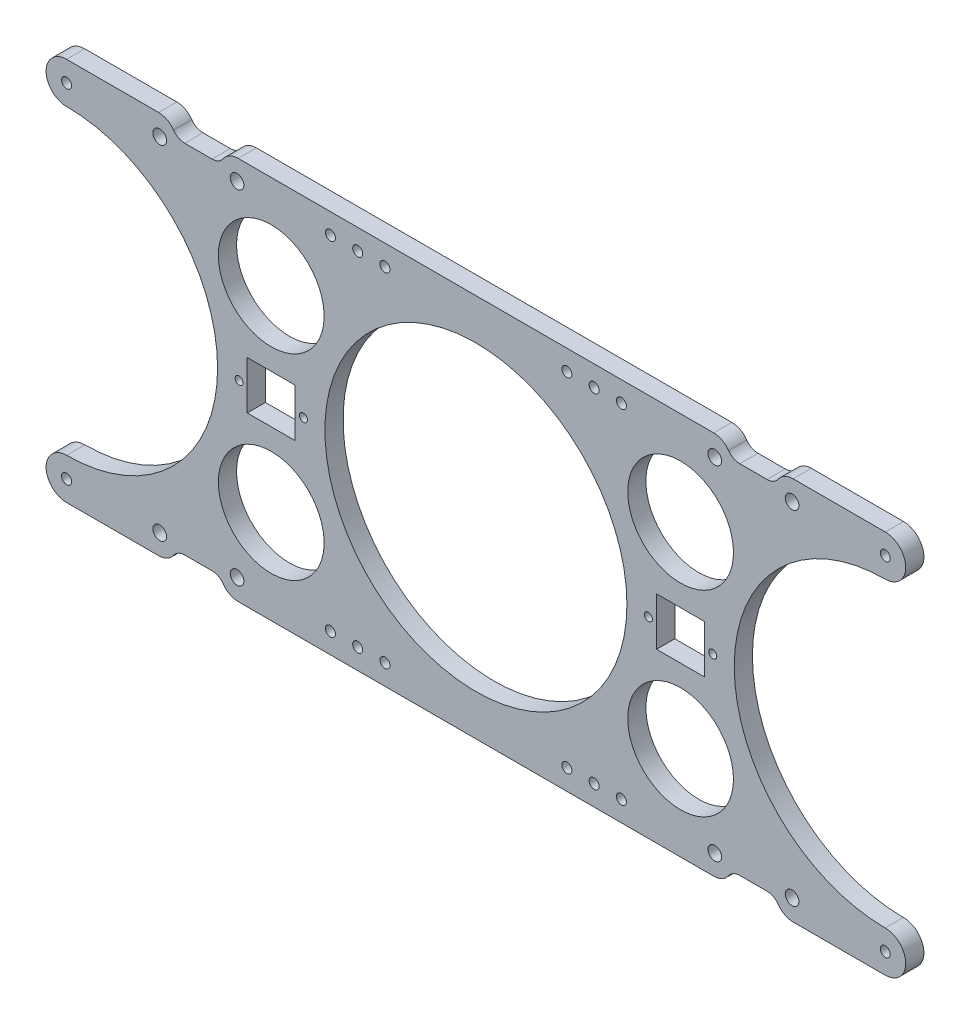
from build123d import *

# Parameters (mm, degrees)
SKETCH1_R            = 83.05
SKETCH1_R_2          = 29.075
SKETCH1_R_3          = 2.2
SKETCH1_R_4          = 3.75
SKETCH1_W            = 26.4
SKETCH1_H            = 26.4
BOSS_EXTRUDE1_DEPTH  = 5
M5_CLEARANCE_HOLE1_D = 5.5
FILLET1_R            = 10


with BuildPart() as part:
    # Sketch1 → Boss-Extrude1 (new body, symmetric)
    with BuildSketch(Plane.XY):
        with BuildLine():
            Line((-225.104242519, 105.55), (-167.604242519, 105.55))
            ThreePointArc((-167.604242519, 105.55), (-165.407543378, 100.246699141), (-160.104242519, 98.05))
            Line((-160.104242519, 98.05), (-145.104242519, 98.05))
            ThreePointArc((-145.104242519, 98.05), (-139.80094166, 100.246699141), (-137.604242519, 105.55))
            Line((-137.604242519, 105.55), (137.604242519, 105.55))
            ThreePointArc((137.604242519, 105.55), (139.80094166, 100.246699141), (145.104242519, 98.05))
            Line((145.104242519, 98.05), (160.104242519, 98.05))
            ThreePointArc((160.104242519, 98.05), (165.407543378, 100.246699141), (167.604242519, 105.55))
            Line((167.604242519, 105.55), (225.104242519, 105.55))
            ThreePointArc((225.104242519, 105.55), (236.354242519, 94.3), (225.104242519, 83.05))
            ThreePointArc((225.104242519, 83.05), (142.054242519, 0), (225.104242519, -83.05))
            ThreePointArc((225.104242519, -83.05), (236.354242519, -94.3), (225.104242519, -105.55))
            Line((225.104242519, -105.55), (167.604242519, -105.55))
            ThreePointArc((167.604242519, -105.55), (165.407543378, -100.246699141), (160.104242519, -98.05))
            Line((160.104242519, -98.05), (145.104242519, -98.05))
            ThreePointArc((145.104242519, -98.05), (139.80094166, -100.246699141), (137.604242519, -105.55))
            Line((137.604242519, -105.55), (-137.604242519, -105.55))
            ThreePointArc((-137.604242519, -105.55), (-139.80094166, -100.246699141), (-145.104242519, -98.05))
            Line((-145.104242519, -98.05), (-160.104242519, -98.05))
            ThreePointArc((-160.104242519, -98.05), (-165.407543378, -100.246699141), (-167.604242519, -105.55))
            Line((-167.604242519, -105.55), (-225.104242519, -105.55))
            ThreePointArc((-225.104242519, -105.55), (-236.354242519, -94.3), (-225.104242519, -83.05))
            ThreePointArc((-225.104242519, -83.05), (-142.054242519, 0), (-225.104242519, 83.05))
            ThreePointArc((-225.104242519, 83.05), (-236.354242519, 94.3), (-225.104242519, 105.55))
        make_face()
        Circle(SKETCH1_R, mode=Mode.SUBTRACT)
        with Locations((112.552121259, 53.975)):
            Circle(SKETCH1_R_2, mode=Mode.SUBTRACT)
        with Locations((112.552121259, -53.975)):
            Circle(SKETCH1_R_2, mode=Mode.SUBTRACT)
        with Locations((-112.552121259, -53.975)):
            Circle(SKETCH1_R_2, mode=Mode.SUBTRACT)
        with Locations((-112.552121259, 53.975)):
            Circle(SKETCH1_R_2, mode=Mode.SUBTRACT)
        with Locations((94.852121259, 0)):
            Circle(SKETCH1_R_3, mode=Mode.SUBTRACT)
        with Locations((130.252121259, 0)):
            Circle(SKETCH1_R_3, mode=Mode.SUBTRACT)
        with Locations((-130.252121259, 0)):
            Circle(SKETCH1_R_3, mode=Mode.SUBTRACT)
        with Locations((-94.852121259, 0)):
            Circle(SKETCH1_R_3, mode=Mode.SUBTRACT)
        with Locations((-173.854242519, 94.3)):
            Circle(SKETCH1_R_4, mode=Mode.SUBTRACT)
        with Locations((-131.354242519, 94.3)):
            Circle(SKETCH1_R_4, mode=Mode.SUBTRACT)
        with Locations((-131.354242519, -94.3)):
            Circle(SKETCH1_R_4, mode=Mode.SUBTRACT)
        with Locations((-173.854242519, -94.3)):
            Circle(SKETCH1_R_4, mode=Mode.SUBTRACT)
        with Locations((131.354242519, -94.3)):
            Circle(SKETCH1_R_4, mode=Mode.SUBTRACT)
        with Locations((173.854242519, -94.3)):
            Circle(SKETCH1_R_4, mode=Mode.SUBTRACT)
        with Locations((131.354242519, 94.3)):
            Circle(SKETCH1_R_4, mode=Mode.SUBTRACT)
        with Locations((173.854242519, 94.3)):
            Circle(SKETCH1_R_4, mode=Mode.SUBTRACT)
        with Locations((-112.552121259, 0)):
            Rectangle(SKETCH1_W, SKETCH1_H, mode=Mode.SUBTRACT)
        with Locations((112.552121259, 0)):
            Rectangle(SKETCH1_W, SKETCH1_H, mode=Mode.SUBTRACT)
    extrude(amount=BOSS_EXTRUDE1_DEPTH, both=True)

    # M5 Clearance Hole1 (through all)
    with Locations(Plane.XY.offset(5)):
        with Locations((-80, 94.3), (-65, 94.3), (-50, 94.3), (50, 94.3), (65, 94.3), (80, 94.3), (-80, -94.3), (-65, -94.3), (-50, -94.3), (50, -94.3), (65, -94.3), (80, -94.3), (0, 0), (-225.104242519, 94.3), (225.104242519, 94.3), (225.104242519, -94.3), (-225.104242519, -94.3)):
            Hole(M5_CLEARANCE_HOLE1_D / 2)

    # Fillet1
    fillet1_edges = [part.edges().sort_by_distance(p)[0] for p in [
        (167.604242519, -105.55, 0),
        (137.604242519, -105.55, 0),
        (-137.604242519, -105.55, 0),
        (-167.604242519, -105.55, 0),
        (-167.604242519, 105.55, 0),
        (-137.604242519, 105.55, 0),
        (137.604242519, 105.55, 0),
        (167.604242519, 105.55, 0),
    ]]
    fillet(fillet1_edges, radius=FILLET1_R)


solid = part.part
